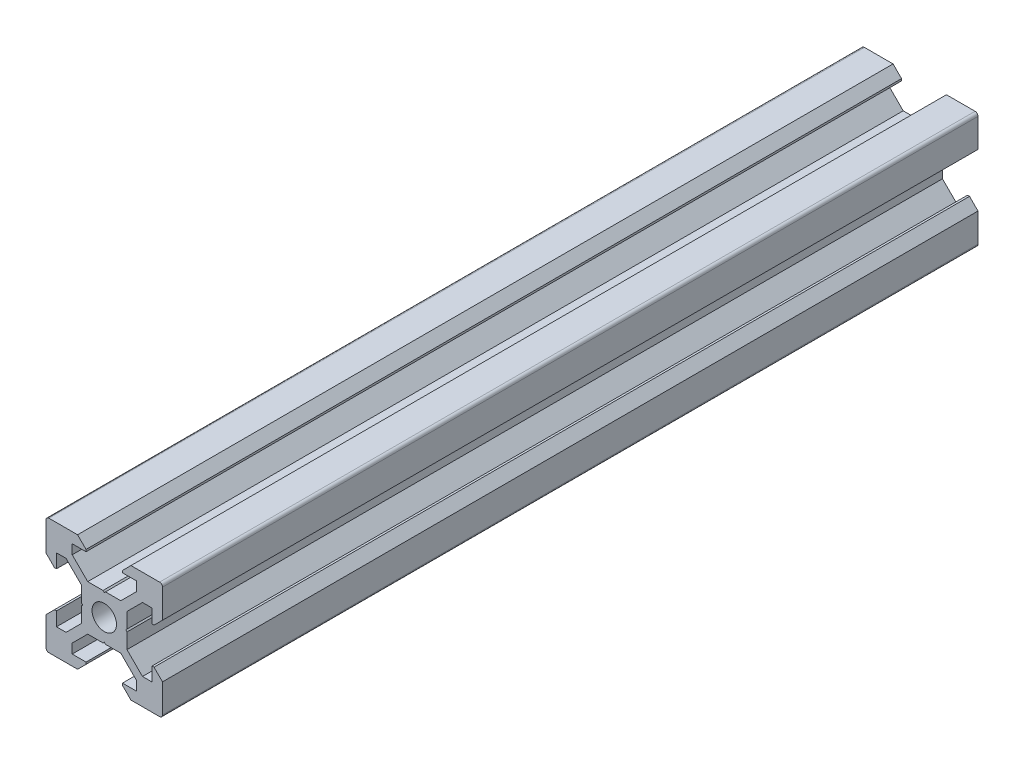
from build123d import *

# Parameters (mm, degrees)
SKETCH1_R           = 2.1
BOSS_EXTRUDE1_DEPTH = 140


with BuildPart() as part:
    # Sketch1 → Boss-Extrude1 (new body)
    with BuildSketch(Plane.XY):
        with BuildLine():
            Line((4.58, -10), (9.5, -10))
            ThreePointArc((9.5, -10), (9.853553391, -9.853553391), (10, -9.5))
            Line((10, -9.5), (10, -4.58))
            Line((10, -4.58), (8.545, -3.125))
            Line((8.545, -3.125), (8.2, -3.125))
            Line((8.2, -3.125), (8.2, -5.5))
            Line((8.2, -5.5), (6.560660172, -5.5))
            Line((6.560660172, -5.5), (3.9, -2.839339828))
            Line((3.9, -2.839339828), (3.9, -0.21))
            Line((3.9, -0.21), (3.69, 0))
            Line((3.69, 0), (3.9, 0.21))
            Line((3.9, 0.21), (3.9, 2.839339828))
            Line((3.9, 2.839339828), (6.560660172, 5.5))
            Line((6.560660172, 5.5), (8.2, 5.5))
            Line((8.2, 5.5), (8.2, 3.125))
            Line((8.2, 3.125), (8.545, 3.125))
            Line((8.545, 3.125), (10, 4.58))
            Line((10, 4.58), (10, 9.5))
            ThreePointArc((10, 9.5), (9.853553391, 9.853553391), (9.5, 10))
            Line((9.5, 10), (4.58, 10))
            Line((4.58, 10), (3.125, 8.545))
            Line((3.125, 8.545), (3.125, 8.2))
            Line((3.125, 8.2), (5.5, 8.2))
            Line((5.5, 8.2), (5.5, 6.560660172))
            Line((5.5, 6.560660172), (2.839339828, 3.9))
            Line((2.839339828, 3.9), (0.21, 3.9))
            Line((0.21, 3.9), (0, 3.69))
            Line((0, 3.69), (-0.21, 3.9))
            Line((-0.21, 3.9), (-2.839339828, 3.9))
            Line((-2.839339828, 3.9), (-5.5, 6.560660172))
            Line((-5.5, 6.560660172), (-5.5, 8.2))
            Line((-5.5, 8.2), (-3.125, 8.2))
            Line((-3.125, 8.2), (-3.125, 8.545))
            Line((-3.125, 8.545), (-4.58, 10))
            Line((-4.58, 10), (-9.5, 10))
            ThreePointArc((-9.5, 10), (-9.853553391, 9.853553391), (-10, 9.5))
            Line((-10, 9.5), (-10, 4.58))
            Line((-10, 4.58), (-8.545, 3.125))
            Line((-8.545, 3.125), (-8.2, 3.125))
            Line((-8.2, 3.125), (-8.2, 5.5))
            Line((-8.2, 5.5), (-6.560660172, 5.5))
            Line((-6.560660172, 5.5), (-3.9, 2.839339828))
            Line((-3.9, 2.839339828), (-3.9, 0.21))
            Line((-3.9, 0.21), (-3.69, 0))
            Line((-3.69, 0), (-3.9, -0.21))
            Line((-3.9, -0.21), (-3.9, -2.839339828))
            Line((-3.9, -2.839339828), (-6.560660172, -5.5))
            Line((-6.560660172, -5.5), (-8.2, -5.5))
            Line((-8.2, -5.5), (-8.2, -3.125))
            Line((-8.2, -3.125), (-8.545, -3.125))
            Line((-8.545, -3.125), (-10, -4.58))
            Line((-10, -4.58), (-10, -9.5))
            ThreePointArc((-10, -9.5), (-9.853553391, -9.853553391), (-9.5, -10))
            Line((-9.5, -10), (-4.58, -10))
            Line((-4.58, -10), (-3.125, -8.545))
            Line((-3.125, -8.545), (-3.125, -8.2))
            Line((-3.125, -8.2), (-5.5, -8.2))
            Line((-5.5, -8.2), (-5.5, -6.560660172))
            Line((-5.5, -6.560660172), (-2.839339828, -3.9))
            Line((-2.839339828, -3.9), (-0.21, -3.9))
            Line((-0.21, -3.9), (0, -3.69))
            Line((0, -3.69), (0.21, -3.9))
            Line((0.21, -3.9), (2.839339828, -3.9))
            Line((2.839339828, -3.9), (5.5, -6.560660172))
            Line((5.5, -6.560660172), (5.5, -8.2))
            Line((5.5, -8.2), (3.125, -8.2))
            Line((3.125, -8.2), (3.125, -8.545))
            Line((3.125, -8.545), (4.58, -10))
        make_face()
        Circle(SKETCH1_R, mode=Mode.SUBTRACT)
    extrude(amount=BOSS_EXTRUDE1_DEPTH)


solid = part.part
